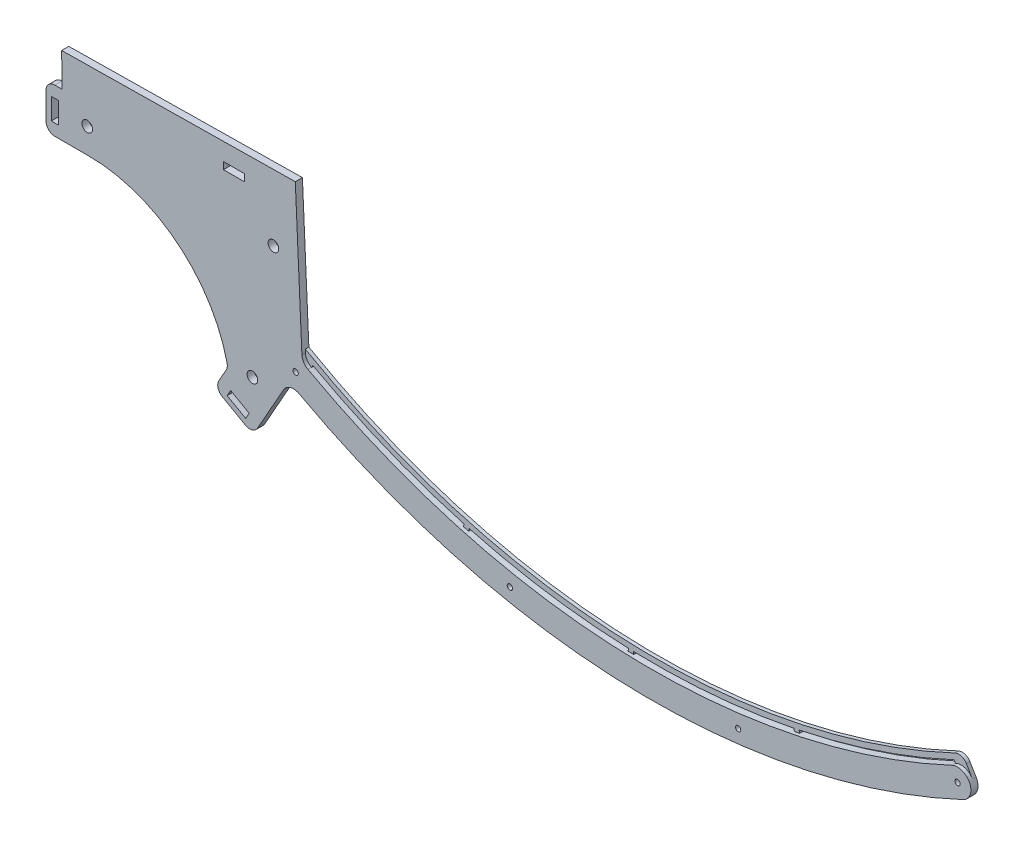
from build123d import *

# Parameters (mm, degrees)
ESQUISSE2_R             = 3
BOSS_EXTRU_1_DEPTH      = 4
ESQUISSE3_R             = 1.5
ENL_V_MAT_EXTRU_1_DEPTH = 5
CONG_1_R                = 6.5
ESQUISSE4_W             = 4
ESQUISSE4_H             = 12
BOSS_EXTRU_2_DEPTH      = 4
CONG_2_R                = 5
ESQUISSE5_W             = 12
ESQUISSE5_H             = 4
ENL_V_MAT_EXTRU_2_DEPTH = 4
BOSS_EXTRU_3_START      = -2
BOSS_EXTRU_3_DEPTH      = 2
CONG_3_R                = 5
BOSS_EXTRU_4_DEPTH      = 2


with BuildPart() as part:
    # Esquisse2 → Boss.-Extru.1 (new body)
    with BuildSketch(Plane.XY):
        with BuildLine():
            Line((-199.971644797, -262.478940861), (-196.098548459, -348.633560192))
            ThreePointArc((-196.098548459, -348.633560192), (-8.923258694, -399.900456932), (180.352503917, -357.033575915))
            Line((180.352503917, -357.033575915), (187.115722814, -370.422335012))
            ThreePointArc((187.115722814, -370.422335012), (-9.257880895, -414.896724067), (-203.452244027, -361.707318699))
            Line((-203.452244027, -361.707318699), (-211.920441681, -376.762493353))
            ThreePointArc((-211.920441681, -376.762493353), (-226.337772202, -383.722686379), (-237.858405423, -372.606089933))
            ThreePointArc((-237.858405423, -372.606089933), (-265.801404699, -326.067035455), (-317.01741072, -308.077718418))
            ThreePointArc((-317.01741072, -308.077718418), (-326.924525304, -304.085923492), (-331.133147983, -294.268956483))
            Line((-331.133147983, -294.268956483), (-331.541895531, -264.271741188))
            Line((-331.541895531, -264.271741188), (-199.971644797, -262.478940861))
        make_face()
        with Locations((-317.134447512, -294.078207627)):
            Circle(ESQUISSE2_R, mode=Mode.SUBTRACT)
        with Locations((-212.300150205, -299.974825982)):
            Circle(ESQUISSE2_R, mode=Mode.SUBTRACT)
        with Locations((-224.122616287, -369.899044157)):
            Circle(ESQUISSE2_R, mode=Mode.SUBTRACT)
    extrude(amount=BOSS_EXTRU_1_DEPTH)

    # Esquisse3 → Enlèv. mat.-Extru.1 (cut, through all)
    with BuildSketch(Plane.XY.offset(4)):
        with BuildLine():
            ThreePointArc((180.352503917, -357.033575915), (175.075442806, -359.650649), (169.760416098, -362.18973084))
            ThreePointArc((169.760416098, -362.18973084), (179.734481353, -365.797780492), (176.126431702, -375.771845747))
            ThreePointArc((176.126431702, -375.771845747), (181.640771911, -373.137548338), (187.115722814, -370.422335012))
            Line((187.115722814, -370.422335012), (180.352503917, -357.033575915))
        make_face()
        with Locations((172.9434239, -368.980788294)):
            Circle(ESQUISSE3_R)
        with Locations((49.352874806, -404.5003631)):
            Circle(ESQUISSE3_R)
        with Locations((-79.152347286, -399.738859656)):
            Circle(ESQUISSE3_R)
        with Locations((-199.775396243, -355.170439446)):
            Circle(ESQUISSE3_R)
    extrude(amount=-ENL_V_MAT_EXTRU_1_DEPTH, mode=Mode.SUBTRACT)

    # Congé1
    cong_1_edges = [part.edges().sort_by_distance(p)[0] for p in [
        (-203.452244027, -361.707318699, 2),
        (-196.098548459, -348.633560192, 2),
    ]]
    fillet(cong_1_edges, radius=CONG_1_R)

    # Esquisse4 → Boss.-Extru.2 (add)
    with BuildSketch(Plane.XY.offset(4)):
        Polygon((-211.920441681, -376.762493353), (-223.686354588, -397.680506965), (-245.4759521, -385.424347686), (-237.96555462, -372.071996878), (-225.374330656, -376.762493353), align=None)
        Polygon((-238.339917634, -385.996197397), (-227.880910828, -391.879153851), (-225.919925343, -388.392818249), (-236.378932149, -382.509861795), align=None, mode=Mode.SUBTRACT)
        Polygon((-316.348629052, -308.074922938), (-340.348629052, -308.074922938), (-340.348629052, -283.074922938), (-331.285679934, -283.074922938), align=None)
        with Locations((-335.348629052, -295.574922938)):
            Rectangle(ESQUISSE4_W, ESQUISSE4_H, mode=Mode.SUBTRACT)
    extrude(amount=-BOSS_EXTRU_2_DEPTH)

    # Congé2
    cong_2_edges = [part.edges().sort_by_distance(p)[0] for p in [
        (-340.348629052, -308.074922938, 2),
        (-340.348629052, -283.074922938, 2),
        (-223.686354588, -397.680506965, 2),
        (-245.4759521, -385.424347686, 2),
        (-237.96555462, -372.071996878, 2),
    ]]
    fillet(cong_2_edges, radius=CONG_2_R)

    # Esquisse5 → Enlèv. mat.-Extru.2 (cut)
    with BuildSketch(Plane.XY.offset(4)):
        with Locations((-234.450045065, -274.867921079)):
            Rectangle(ESQUISSE5_W, ESQUISSE5_H)
    extrude(amount=-ENL_V_MAT_EXTRU_2_DEPTH, mode=Mode.SUBTRACT)

    # Esquisse6 → Boss.-Extru.3 (add)
    with BuildSketch(Plane.XY.offset(4).offset(BOSS_EXTRU_3_START)):
        with BuildLine():
            Line((169.003770429, -360.887760364), (169.760416098, -362.18973084))
            Line((169.760416098, -362.18973084), (178.042128837, -365.922078374))
            Line((178.042128837, -365.922078374), (179.374906332, -365.122545984))
            Line((179.374906332, -365.122545984), (173.538532023, -355.393623893))
            ThreePointArc((173.538532023, -355.393623893), (-12.898010177, -395.289629681), (-196.337202457, -343.324850443))
            Line((-196.337202457, -343.324850443), (-200.18270603, -348.6233841))
            Line((-200.18270603, -348.6233841), (-194.097457315, -353.368142853))
            Line((-194.097457315, -353.368142853), (-192.138010837, -349.120659359))
            ThreePointArc((-192.138010837, -349.120659359), (-12.977458778, -398.288633485), (169.003770429, -360.887760364))
        make_face()
    extrude(amount=-BOSS_EXTRU_3_DEPTH)

    # Congé3
    cong_3_edges = [part.edges().sort_by_distance(p)[0] for p in [
        (173.538532023, -355.393623893, 1),
    ]]
    fillet(cong_3_edges, radius=CONG_3_R)

    # Esquisse8 → Boss.-Extru.4 (add)
    with BuildSketch(Plane(origin=(0, 0, 0), x_dir=(-1, 0, 0), z_dir=(0, 0, -1))):
        Polygon((11.706214766, -405.333769301), (11.38055708, -395.339073354), (14.378965864, -395.241376048), (14.70462355, -405.236071995), align=None)
        Polygon((-83.101661868, -396.896225473), (-81.088533104, -387.100955565), (-78.149952132, -387.704894194), (-80.163080896, -397.500164102), align=None)
        Polygon((105.869114928, -391.438667615), (103.22261353, -381.795222673), (106.115647013, -381.001272254), (108.76214841, -390.644717196), align=None)
    extrude(amount=-BOSS_EXTRU_4_DEPTH)


solid = part.part
